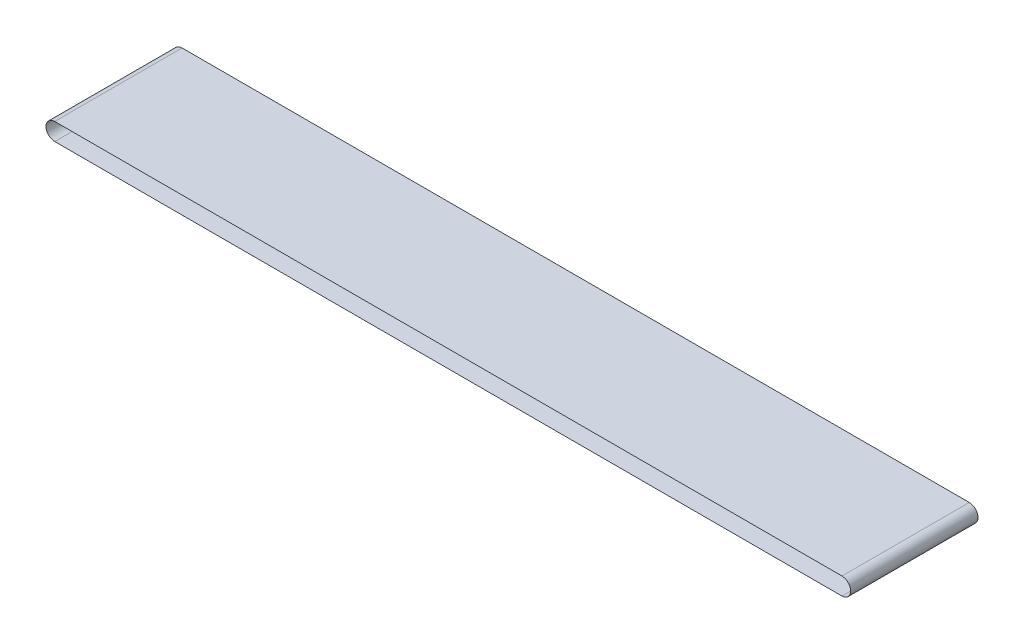
from build123d import *

# Parameters (mm, degrees)
BOSS_EXTRUDE1_DEPTH = 550
SHELL1_T            = -0.002


with BuildPart() as part:
    # Sketch1 → Boss-Extrude1 (new body)
    with BuildSketch(Plane.XY):
        with BuildLine():
            Line((-3124.739682402, 50), (275.260317598, 50))
            ThreePointArc((275.260317598, 50), (312.760317598, 12.5), (275.260317598, -25))
            Line((275.260317598, -25), (-3124.739682402, -25))
            ThreePointArc((-3124.739682402, -25), (-3162.239682402, 12.5), (-3124.739682402, 50))
        make_face()
    extrude(amount=BOSS_EXTRUDE1_DEPTH)

    # Shell1
    shell1_openings = [part.faces().sort_by_distance(p)[0] for p in [
        (-1424.739682402, 12.5, 550),
        (-1424.739682402, 12.5, 0),
    ]]
    offset(amount=SHELL1_T, openings=shell1_openings, kind=Kind.INTERSECTION)


solid = part.part
